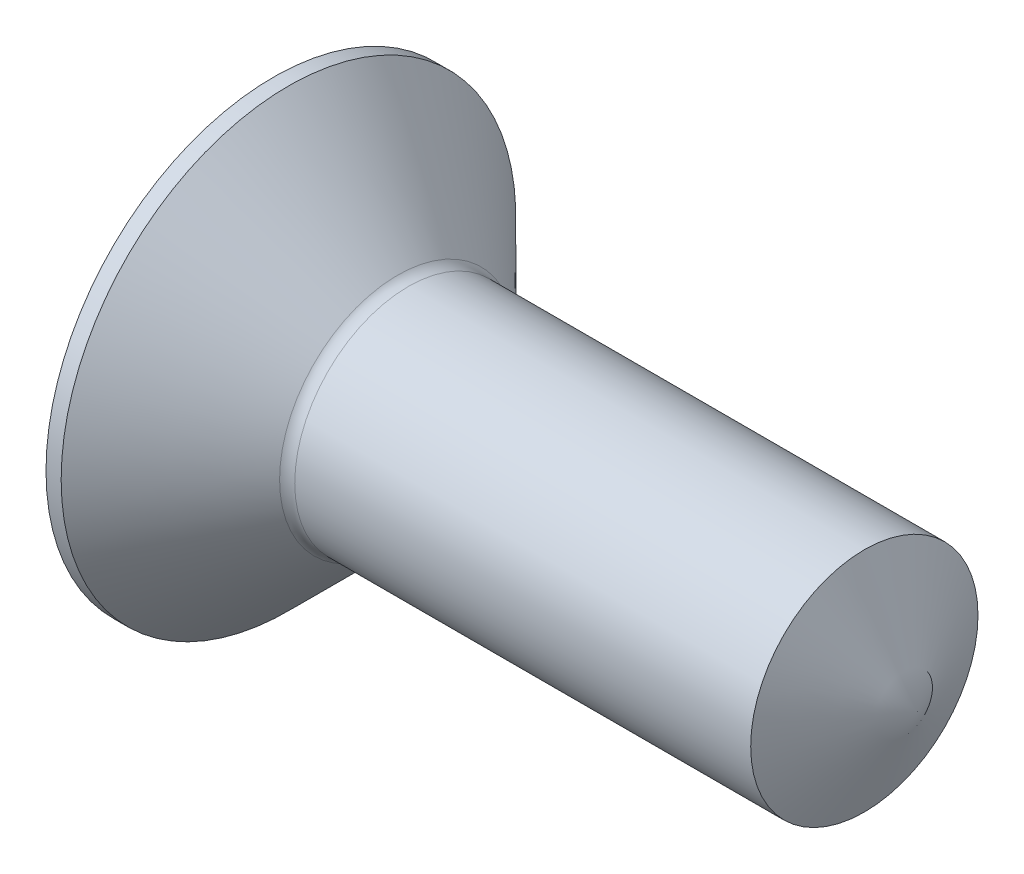
from build123d import *

# Parameters (mm, degrees)
FILLET2_R = 0.2


with BuildPart() as part:
    # Sketch1 → Base (revolve)
    with BuildSketch(Plane(origin=(0, 0, 0), x_dir=(1, 0, 0), z_dir=(0, 1, 0))):
        Polygon((1.7, 1.5), (8.5, 1.5), (8.5, 0), (0, 0), (0, 3), (0.2, 3), align=None)
    revolve(axis=Axis((-6.506452013, 0, 0), (1, 0, 0)))

    # Sketch3 → Cut-Revolve1 (revolve, cut)
    with BuildSketch(Plane.XY):
        Polygon((8.65755877, 0), (8.65755877, 20), (-0.826153163, 20), (8.5, 0), align=None)
    revolve(axis=Axis((4.883468835, 0, 0), (1, 0, 0)), mode=Mode.SUBTRACT)

    # Fillet2
    fillet2_edges = [part.edges().sort_by_distance(p)[0] for p in [
        (1.7, 0, 1.5),
    ]]
    fillet(fillet2_edges, radius=FILLET2_R)

    # Sketch2 → Cut-Loft1 section 0
    with BuildSketch(Plane(origin=(0, -0.680816871, 0.306758275), x_dir=(0, 0, 1), z_dir=(-1, 0, 0)), mode=Mode.PRIVATE) as cut_loft1_s0:
        Polygon((-0.686758275, 1.060816871), (-2.206758275, 1.060816871), (-2.206758275, 0.300816871), (-0.686758275, 0.300816871), (-0.686758275, -1.219183129), (0.073241725, -1.219183129), (0.073241725, 0.300816871), (1.593241725, 0.300816871), (1.593241725, 1.060816871), (0.073241725, 1.060816871), (0.073241725, 2.580816871), (-0.686758275, 2.580816871), align=None)
    loft([cut_loft1_s0.sketch, Vertex(1.95, 0, 0)], mode=Mode.SUBTRACT)


solid = part.part
